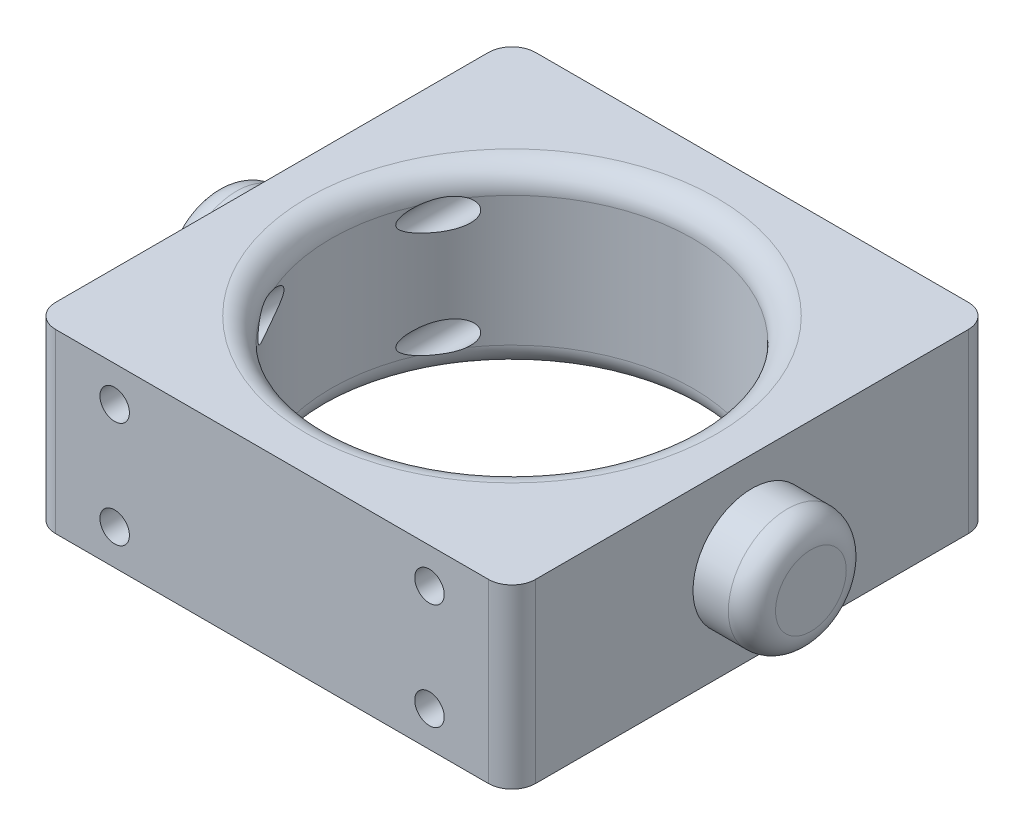
from build123d import *

# Parameters (mm, degrees)
SKETCH1_W                       = 40.7
SKETCH1_H                       = 40.7
SKETCH1_R                       = 15.35
BOSS_EXTRUDE1_DEPTH             = 15
SKETCH2_R                       = 5
BOSS_EXTRUDE2_DEPTH             = 5
FILLET1_R                       = 2
FILLET2_R                       = 2
TAP_DRILL_FOR_M3X0_5_TAP1_D     = 2.5
TAP_DRILL_FOR_M3X0_5_TAP1_DEPTH = 20.349
TAP_DRILL_FOR_M3X0_5_TAP1_TIP   = 0.751075774
TAP_DRILL_FOR_M3X0_5_TAP2_D     = 2.5
TAP_DRILL_FOR_M3X0_5_TAP2_DEPTH = 20.35
TAP_DRILL_FOR_M3X0_5_TAP2_TIP   = 0.751075774


with BuildPart() as part:
    # Sketch1 → Boss-Extrude1 (new body)
    with BuildSketch(Plane(origin=(0, 0, 0), x_dir=(1, 0, 0), z_dir=(0, 1, 0))):
        Rectangle(SKETCH1_W, SKETCH1_H)
        with Locations(Location((0, 0, 0), (0, 0, 270))):  # turned: the seam where the file's is
            Circle(SKETCH1_R, mode=Mode.SUBTRACT)
    extrude(amount=BOSS_EXTRUDE1_DEPTH)

    # Sketch2 → Boss-Extrude2 (add)
    with BuildSketch(Plane.ZY.offset(20.35)):
        with Locations(Location((0, 7.5, 0), (0, 0, 180))):  # turned: the seam where the file's is
            Circle(SKETCH2_R)
    boss_extrude2 = extrude(amount=BOSS_EXTRUDE2_DEPTH)

    # Mirror1: Boss-Extrude2 across plane
    add(boss_extrude2.mirror(Plane.ZY))

    # Fillet1
    fillet1_edges = [part.edges().sort_by_distance(p)[0] for p in [
        (0, 0, -15.35),
        (0, 15, -15.35),
        (20.35, 7.5, 20.35),
        (-20.35, 7.5, 20.35),
        (-20.35, 7.5, -20.35),
        (20.35, 7.5, -20.35),
    ]]
    fillet(fillet1_edges, radius=FILLET1_R)

    # Fillet2
    fillet2_edges = [part.edges().sort_by_distance(p)[0] for p in [
        (-25.35, 7.5, 5),
        (25.35, 7.5, 5),
    ]]
    fillet(fillet2_edges, radius=FILLET2_R)

    # Tap Drill for M3x0.5 Tap1
    with Locations(Plane.XY.offset(20.35)):
        with Locations((-13.35, 12), (-13.35, 3), (13.35, 12), (13.35, 3)):
            Hole(TAP_DRILL_FOR_M3X0_5_TAP1_D / 2, depth=TAP_DRILL_FOR_M3X0_5_TAP1_DEPTH)
            with Locations((0, 0, -(TAP_DRILL_FOR_M3X0_5_TAP1_DEPTH + TAP_DRILL_FOR_M3X0_5_TAP1_TIP / 2))):  # 118° drill point
                Cone(0, TAP_DRILL_FOR_M3X0_5_TAP1_D / 2, TAP_DRILL_FOR_M3X0_5_TAP1_TIP, mode=Mode.SUBTRACT)

    # Tap Drill for M3x0.5 Tap2
    with Locations(Plane(origin=(0, 0, -20.35), x_dir=(-1, 0, 0), z_dir=(0, 0, -1))):
        with Locations((-13.35, 12), (-13.35, 3), (13.35, 12), (13.35, 3)):
            Hole(TAP_DRILL_FOR_M3X0_5_TAP2_D / 2, depth=TAP_DRILL_FOR_M3X0_5_TAP2_DEPTH)
            with Locations((0, 0, -(TAP_DRILL_FOR_M3X0_5_TAP2_DEPTH + TAP_DRILL_FOR_M3X0_5_TAP2_TIP / 2))):  # 118° drill point
                Cone(0, TAP_DRILL_FOR_M3X0_5_TAP2_D / 2, TAP_DRILL_FOR_M3X0_5_TAP2_TIP, mode=Mode.SUBTRACT)


solid = part.part
